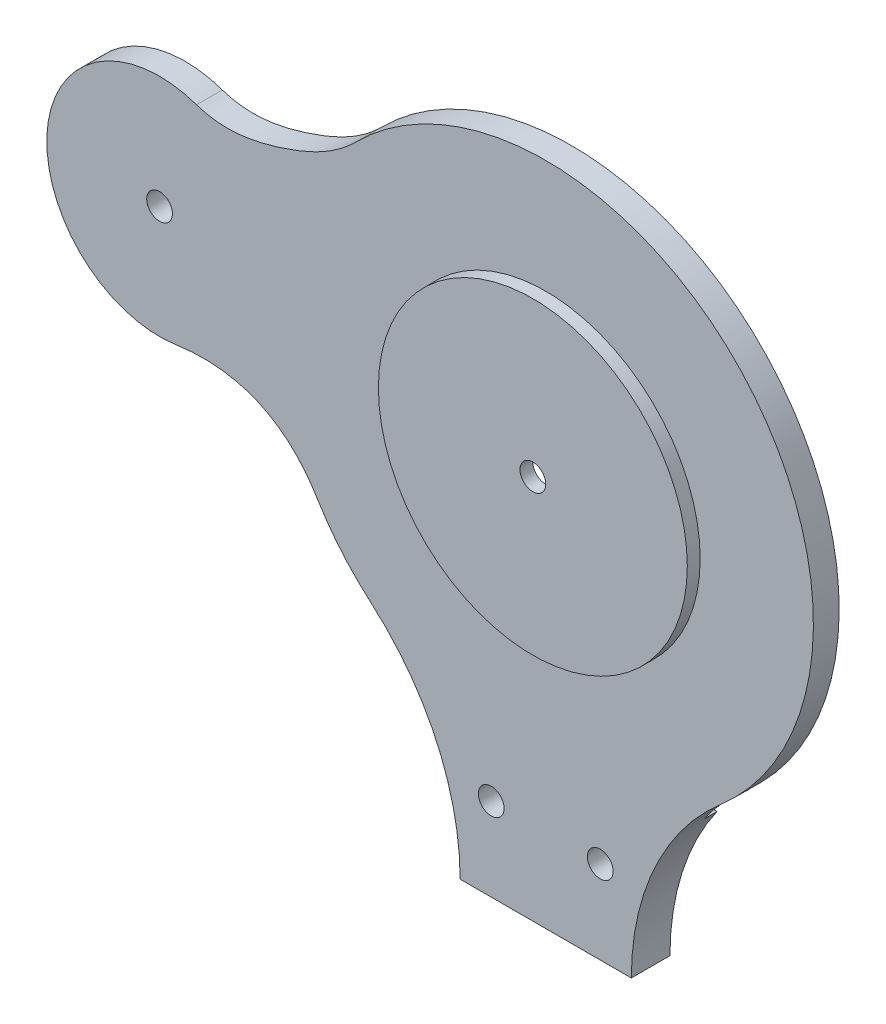
from build123d import *

# Parameters (mm, degrees)
SKETCH1_R           = 24.455055929
SKETCH1_R_2         = 2.54
BOSS_EXTRUDE1_DEPTH = 5.08
SKETCH4_R           = 30.48
BOSS_EXTRUDE3_DEPTH = 2.54
SKETCH5_R           = 2.54
CUT_EXTRUDE2_DEPTH  = 8.62
SKETCH6_R           = 45.336039437
SKETCH6_R_2         = 37.958395775
BOSS_EXTRUDE4_DEPTH = 2.54
SKETCH7_R           = 2.54
CUT_EXTRUDE3_DEPTH  = 3.54
BOSS_EXTRUDE6_DEPTH = 5.08
SKETCH11_R          = 2.54
CUT_EXTRUDE4_DEPTH  = 8.62


with BuildPart() as part:
    # Sketch1 → Boss-Extrude1 (new body)
    with BuildSketch(Plane.XY):
        with BuildLine():
            Line((-16.891, -131.282672274), (16.891, -131.282672274))
            ThreePointArc((16.891, -131.282672274), (21.504350582, -110.13005032), (34.5064888, -92.819336271))
            ThreePointArc((34.5064888, -92.819336271), (0, 0), (-34.5064888, -92.819336271))
            ThreePointArc((-34.5064888, -92.819336271), (-21.504350582, -110.13005032), (-16.891, -131.282672274))
        make_face()
        with Locations((0, -52.823729134)):
            Circle(SKETCH1_R, mode=Mode.SUBTRACT)
        with Locations((-10.756405179, -114.872047193)):
            Circle(SKETCH1_R_2, mode=Mode.SUBTRACT)
        with Locations((10.756405179, -114.872047193)):
            Circle(SKETCH1_R_2, mode=Mode.SUBTRACT)
    extrude(amount=BOSS_EXTRUDE1_DEPTH)

    # Sketch4 → Boss-Extrude3 (add)
    with BuildSketch(Plane.XY.offset(5.08)):
        with Locations((0, -52.823729134)):
            Circle(SKETCH4_R)
    extrude(amount=BOSS_EXTRUDE3_DEPTH)

    # Sketch5 → Cut-Extrude2 (cut, through all)
    with BuildSketch(Plane.XY.offset(7.62)):
        with Locations((0, -52.823729134)):
            Circle(SKETCH5_R)
    extrude(amount=-CUT_EXTRUDE2_DEPTH, mode=Mode.SUBTRACT)

    # Sketch6 → Boss-Extrude4 (add)
    with BuildSketch(Plane(origin=(0, 0, 0), x_dir=(-1, 0, 0), z_dir=(0, 0, -1))):
        with Locations((0, -52.823729134)):
            Circle(SKETCH6_R)
        with Locations((0, -52.823729134)):
            Circle(SKETCH6_R_2, mode=Mode.SUBTRACT)
        with BuildLine():
            Line((16.891, -131.282672274), (-16.891, -131.282672274))
            ThreePointArc((-16.891, -131.282672274), (-19.272918471, -115.909664076), (-26.19530634, -101.978279981))
            Line((-26.19530634, -101.978279981), (26.19530634, -101.978279981))
            ThreePointArc((26.19530634, -101.978279981), (19.272918471, -115.909664076), (16.891, -131.282672274))
        make_face()
    extrude(amount=BOSS_EXTRUDE4_DEPTH)

    # Sketch7 → Cut-Extrude3 (cut, through all)
    with BuildSketch(Plane.XY):
        with Locations((-10.756405179, -114.872047193)):
            Circle(SKETCH7_R)
        with Locations((10.756405179, -114.872047193)):
            Circle(SKETCH7_R)
    extrude(amount=-CUT_EXTRUDE3_DEPTH, mode=Mode.SUBTRACT)

    # Sketch10 → Boss-Extrude6 (add)
    with BuildSketch(Plane.XY.offset(5.08)):
        with BuildLine():
            add(Edge.make_bspline(
                [(-68.900180003, -24.949874899), (-63.297197231, -26.895437115), (-51.389708048, -24.415182371), (-41.569282444, -19.727412804), (-37.524583334, -15.645079276)],
                knots=[0, 0, 0, 0, 0.520070067, 1, 1, 1, 1], degree=3))
            ThreePointArc((-68.900180003, -24.949874899), (-98.354072, -43.866775297), (-72.9914133, -67.993864183))
            add(Edge.make_bspline(
                [(-72.9914133, -67.993864183), (-65.508215076, -66.903538588), (-55.033388576, -68.640688731), (-47.574313167, -76.247284621), (-45.161811227, -80.223677424)],
                knots=[0, 0, 0, 0, 0.604504859, 1, 1, 1, 1], degree=3))
            ThreePointArc((-45.161811227, -80.223677424), (-52.45816234, -46.619894549), (-37.524583334, -15.645079276))
        make_face()
    extrude(amount=-BOSS_EXTRUDE6_DEPTH)

    # Sketch11 → Cut-Extrude4 (cut, through all)
    with BuildSketch(Plane.XY.offset(5.08)):
        with Locations((-76.2, -45.972469461)):
            Circle(SKETCH11_R)
    extrude(amount=-CUT_EXTRUDE4_DEPTH, mode=Mode.SUBTRACT)


solid = part.part
